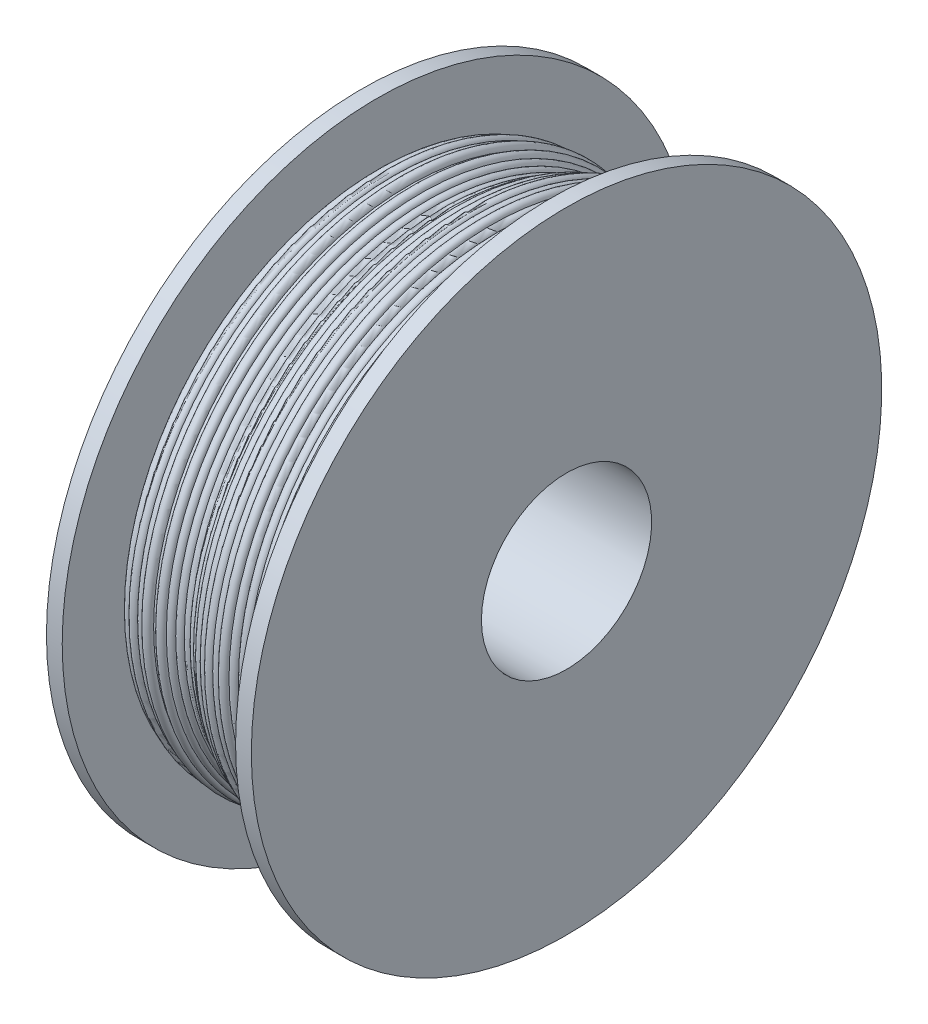
from build123d import *


with BuildPart() as part:
    # Croquis1 → Revolución1 (revolve)
    with BuildSketch(Plane.XY):
        Polygon((-27.5, 0), (-27.5, 68), (27.5, 68), (27.5, 0), (32.5, 0), (32.5, 73), (-32.5, 73), (-32.5, 0), align=None)
    revolve(axis=Axis((-54.879014488, 100, 0), (1, 0, 0)))


with BuildPart() as body_2:
    # Croquis2 → Revolución2 (revolve)
    with BuildSketch(Plane.XY):
        with BuildLine():
            Line((-27.5, 20.343906075), (-27.5, 68))
            Line((-27.5, 68), (27.5, 68))
            Line((27.5, 68), (27.5, 19.194100614))
            ThreePointArc((27.5, 19.194100614), (26.437145923, 17.759212659), (24.75479541, 18.357760055))
            ThreePointArc((24.75479541, 18.357760055), (23.756736143, 17.517576452), (22.478140818, 17.776853872))
            ThreePointArc((22.478140818, 17.776853872), (21.433338426, 16.889745452), (20.103656018, 17.222188055))
            ThreePointArc((20.103656018, 17.222188055), (18.860208202, 16.378724899), (17.50930197, 17.036482396))
            ThreePointArc((17.50930197, 17.036482396), (15.952287588, 16.407960316), (14.787730947, 17.617564228))
            ThreePointArc((14.787730947, 17.617564228), (13.933650564, 17.48541761), (13.14842151, 17.846431961))
            ThreePointArc((13.14842151, 17.846431961), (11.972017579, 17.152504471), (10.720716957, 17.6999607))
            ThreePointArc((10.720716957, 17.6999607), (9.815532626, 16.771350143), (8.524688404, 16.895436542))
            ThreePointArc((8.524688404, 16.895436542), (7.351850735, 15.643084204), (5.771196412, 16.310516962))
            ThreePointArc((5.771196412, 16.310516962), (4.847855043, 15.999263565), (3.928099514, 16.320958652))
            ThreePointArc((3.928099514, 16.320958652), (2.292606148, 15.654185737), (1.156227442, 17.006246427))
            ThreePointArc((1.156227442, 17.006246427), (-0.216631512, 16.745376394), (-1.208786715, 17.729461215))
            ThreePointArc((-1.208786715, 17.729461215), (-2.736842083, 17.637218527), (-3.550093494, 18.934170362))
            ThreePointArc((-3.550093494, 18.934170362), (-4.873326013, 19.081885736), (-5.557777818, 20.223940839))
            ThreePointArc((-5.557777818, 20.223940839), (-6.821927847, 20.101011604), (-7.727198225, 20.991894556))
            ThreePointArc((-7.727198225, 20.991894556), (-8.650973187, 20.591506396), (-9.619815923, 20.865394349))
            ThreePointArc((-9.619815923, 20.865394349), (-10.504891979, 20.089563123), (-11.677458022, 20.191359928))
            ThreePointArc((-11.677458022, 20.191359928), (-12.468950314, 19.260878352), (-13.69007839, 19.227678464))
            ThreePointArc((-13.69007839, 19.227678464), (-15.229506095, 17.941410973), (-16.671294323, 19.336247316))
            ThreePointArc((-16.671294323, 19.336247316), (-17.128160725, 19.150354889), (-17.620621833, 19.122696971))
            ThreePointArc((-17.620621833, 19.122696971), (-18.799537302, 17.504113334), (-20.536944377, 18.49963899))
            ThreePointArc((-20.536944377, 18.49963899), (-21.475405343, 18.324686764), (-22.329369386, 18.751374802))
            ThreePointArc((-22.329369386, 18.751374802), (-23.859458197, 17.953504754), (-25.12788082, 19.123492974))
            ThreePointArc((-25.12788082, 19.123492974), (-26.686229273, 19.010080979), (-27.5, 20.343906075))
        make_face()
    revolve(axis=Axis((-32.5, 100, 0), (1, 0, 0)))


solid = Compound([part.part, body_2.part])
